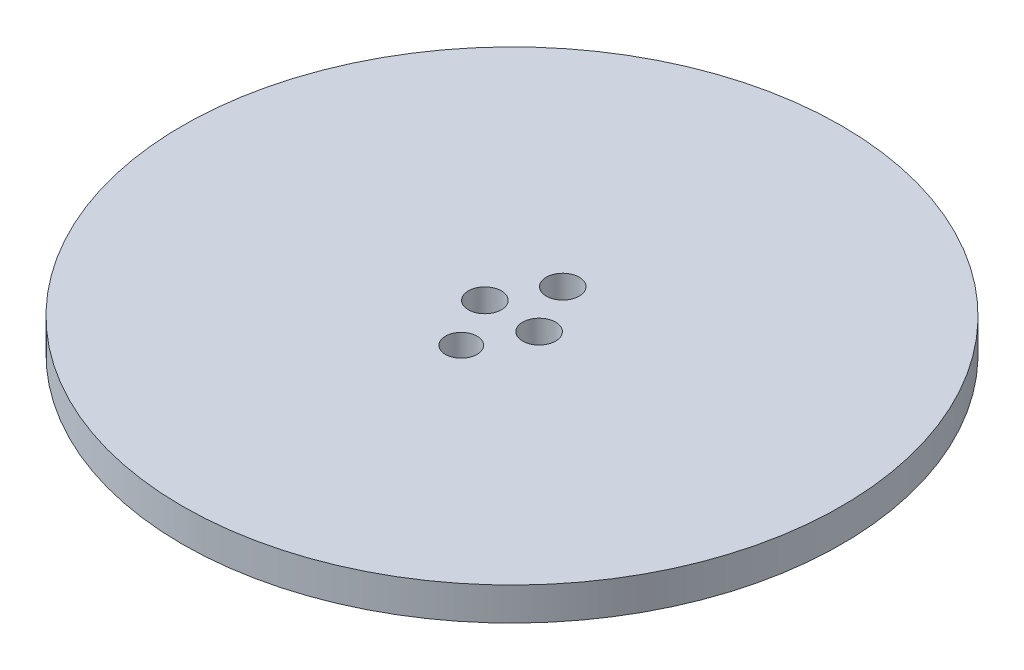
from build123d import *

# Parameters (mm, degrees)
SKETCH1_R           = 15.875
BOSS_EXTRUDE1_DEPTH = 6.35
SKETCH2_R           = 63.5
BOSS_EXTRUDE2_DEPTH = 6.35
SKETCH9_R           = 3.048
CUT_EXTRUDE1_DEPTH  = 13.7
SKETCH10_R          = 3.175
CUT_EXTRUDE2_DEPTH  = 12.7
SKETCH11_R          = 3.175
CUT_EXTRUDE3_DEPTH  = 12.7
SKETCH12_R          = 3.175
CUT_EXTRUDE4_DEPTH  = 12.7


with BuildPart() as part:
    # Sketch1 → Boss-Extrude1 (new body)
    with BuildSketch(Plane(origin=(0, 0, 0), x_dir=(1, 0, 0), z_dir=(0, 1, 0))):
        Circle(SKETCH1_R)
    extrude(amount=BOSS_EXTRUDE1_DEPTH)

    # Sketch2 → Boss-Extrude2 (add)
    with BuildSketch(Plane(origin=(0, 6.35, 0), x_dir=(1, 0, 0), z_dir=(0, 1, 0))):
        Circle(SKETCH2_R)
    extrude(amount=BOSS_EXTRUDE2_DEPTH)

    # Sketch9 → Cut-Extrude1 (cut, through all)
    with BuildSketch(Plane.XZ):
        with Locations((0, 9.779)):
            Circle(SKETCH9_R)
    extrude(amount=-CUT_EXTRUDE1_DEPTH, mode=Mode.SUBTRACT)

    # Sketch10 → Cut-Extrude2 (cut)
    with BuildSketch(Plane.XZ):
        with Locations((0, -9.779)):
            Circle(SKETCH10_R)
    extrude(amount=-CUT_EXTRUDE2_DEPTH, mode=Mode.SUBTRACT)

    # Sketch11 → Cut-Extrude3 (cut)
    with BuildSketch(Plane.XZ):
        with Locations((-5.22478, 0)):
            Circle(SKETCH11_R)
    extrude(amount=-CUT_EXTRUDE3_DEPTH, mode=Mode.SUBTRACT)

    # Sketch12 → Cut-Extrude4 (cut)
    with BuildSketch(Plane.XZ):
        with Locations((5.22478, 0)):
            Circle(SKETCH12_R)
    extrude(amount=-CUT_EXTRUDE4_DEPTH, mode=Mode.SUBTRACT)


solid = part.part
